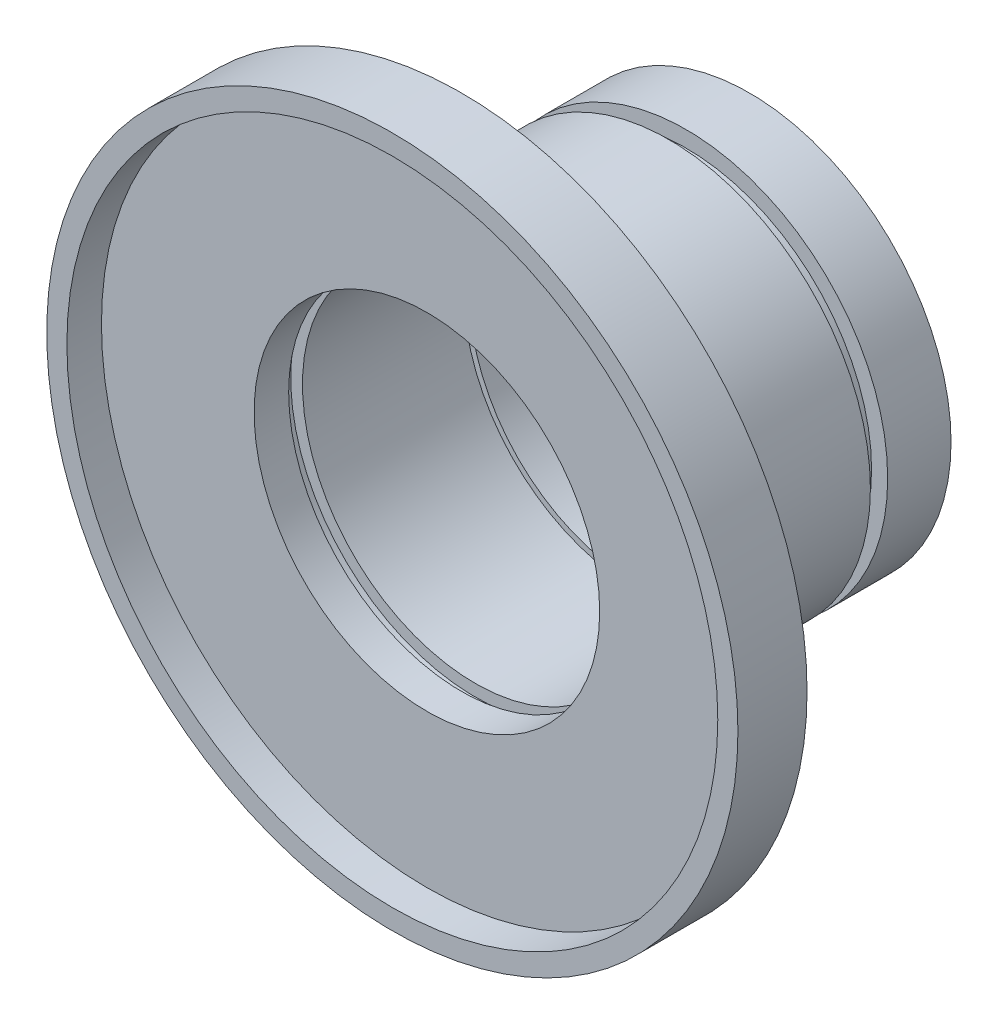
from build123d import *

# Parameters (mm, degrees)
SKETCH_1_R          = 30
SKETCH_1_R_2        = 28.251
EXTRUDE_1_DEPTH     = 3
SKETCH_2_R          = 30
SKETCH_2_R_2        = 15
EXTRUDE_2_DEPTH     = 3
SKETCH_4_R          = 17.5
SKETCH_4_R_2        = 15
EXTRUDE_3_DEPTH     = 20
SKETCH_5_R          = 17.5
SKETCH_5_R_2        = 14.5
EXTRUDE_4_DEPTH     = 0.5
SKETCH_6_W          = 1.5
SKETCH_6_H          = 1.4
SKETCH_7_W          = 1.2
SKETCH_7_H          = 1.05
SKETCH_8_R          = 15
SKETCH_8_R_2        = 14.5
EXTRUDE_5_DEPTH     = 4.8
SKETCH_9_R          = 17.5
SKETCH_9_R_2        = 11.5
EXTRUDE_6_DEPTH     = 4.5
CUT_EXTRUDE_1_DEPTH = 5


with BuildPart() as part:
    # 草图1 → 凸台-拉伸1 (new body)
    with BuildSketch(Plane.XY):
        Circle(SKETCH_1_R)
        Circle(SKETCH_1_R_2, mode=Mode.SUBTRACT)
    extrude(amount=EXTRUDE_1_DEPTH)

    # 草图2 → 凸台-拉伸2 (add)
    with BuildSketch(Plane.XY):
        Circle(SKETCH_2_R)
        Circle(SKETCH_2_R_2, mode=Mode.SUBTRACT)
    extrude(amount=-EXTRUDE_2_DEPTH)

    # 草图4 → 凸台-拉伸3 (add)
    with BuildSketch(Plane(origin=(0, 0, -3), x_dir=(-1, 0, 0), z_dir=(0, 0, -1))):
        Circle(SKETCH_4_R)
        Circle(SKETCH_4_R_2, mode=Mode.SUBTRACT)
    extrude(amount=EXTRUDE_3_DEPTH)

    # 草图5 → 凸台-拉伸4 (add)
    with BuildSketch(Plane(origin=(0, 0, -23), x_dir=(-1, 0, 0), z_dir=(0, 0, -1))):
        Circle(SKETCH_5_R)
        Circle(SKETCH_5_R_2, mode=Mode.SUBTRACT)
    extrude(amount=EXTRUDE_4_DEPTH)

    # 草图6 → 切除-旋转1 (revolve, cut)
    with BuildSketch(Plane(origin=(0, 0, 0), x_dir=(0, 0, -1), z_dir=(1, 0, 0))):
        with Locations((21.75, 16.8)):
            Rectangle(SKETCH_6_W, SKETCH_6_H)
    revolve(axis=Axis((0, 0, 3), (0, 0, -1)), mode=Mode.SUBTRACT)

    # 草图7 → 切除-旋转2 (revolve, cut)
    with BuildSketch(Plane(origin=(0, 0, 0), x_dir=(0, 0, -1), z_dir=(1, 0, 0))):
        with Locations((3.6, 15.498648932)):
            Rectangle(SKETCH_7_W, SKETCH_7_H)
    revolve(axis=Axis((0, 0, 3), (0, 0, -1)), mode=Mode.SUBTRACT)

    # 草图8 → 凸台-拉伸5 (add)
    with BuildSketch(Plane(origin=(0, 0, -23), x_dir=(-1, 0, 0), z_dir=(0, 0, -1))):
        Circle(SKETCH_8_R)
        Circle(SKETCH_8_R_2, mode=Mode.SUBTRACT)
    extrude(amount=-EXTRUDE_5_DEPTH)

    # 草图9 → 凸台-拉伸6 (add)
    with BuildSketch(Plane(origin=(0, 0, -23.5), x_dir=(-1, 0, 0), z_dir=(0, 0, -1))):
        Circle(SKETCH_9_R)
        Circle(SKETCH_9_R_2, mode=Mode.SUBTRACT)
    extrude(amount=EXTRUDE_6_DEPTH)

    # 草图10 → 切除-拉伸1 (cut)
    with BuildSketch(Plane(origin=(0, 0, -28), x_dir=(-1, 0, 0), z_dir=(0, 0, -1))):
        with BuildLine():
            ThreePointArc((-1.5, 11.401754251), (0, 11.5), (1.5, 11.401754251))
            Line((1.5, 11.401754251), (1.5, 13.5))
            Line((1.5, 13.5), (1.5, 15.427248621))
            ThreePointArc((1.5, 15.427248621), (0, 15.5), (-1.5, 15.427248621))
            Line((-1.5, 15.427248621), (-1.5, 13.5))
            Line((-1.5, 13.5), (-1.5, 11.401754251))
        make_face()
        with BuildLine():
            Line((6.414586205, 14.110389216), (5.450961894, 12.441342951))
            Line((5.450961894, 12.441342951), (4.40183902, 10.624208829))
            ThreePointArc((4.40183902, 10.624208829), (5.75, 9.959292144), (6.999915231, 9.124208829))
            Line((6.999915231, 9.124208829), (8.049038106, 10.941342951))
            Line((8.049038106, 10.941342951), (9.012662416, 12.610389216))
            ThreePointArc((9.012662416, 12.610389216), (7.75, 13.423393759), (6.414586205, 14.110389216))
        make_face()
        with BuildLine():
            Line((10.941342951, 8.049038106), (9.124208829, 6.999915231))
            ThreePointArc((9.124208829, 6.999915231), (9.959292144, 5.75), (10.624208829, 4.40183902))
            Line((10.624208829, 4.40183902), (12.441342951, 5.450961894))
            Line((12.441342951, 5.450961894), (14.110389216, 6.414586205))
            ThreePointArc((14.110389216, 6.414586205), (13.423393759, 7.75), (12.610389216, 9.012662416))
            Line((12.610389216, 9.012662416), (10.941342951, 8.049038106))
        make_face()
        with BuildLine():
            Line((13.5, 1.5), (11.401754251, 1.5))
            ThreePointArc((11.401754251, 1.5), (11.475412278, 0.751606983), (11.5, 0))
            ThreePointArc((11.5, 0), (11.475412278, -0.751606983), (11.401754251, -1.5))
            Line((11.401754251, -1.5), (13.5, -1.5))
            Line((13.5, -1.5), (15.427248621, -1.5))
            ThreePointArc((15.427248621, -1.5), (15.481801472, -0.750881609), (15.5, 0))
            ThreePointArc((15.5, 0), (15.481801472, 0.750881609), (15.427248621, 1.5))
            Line((15.427248621, 1.5), (13.5, 1.5))
        make_face()
        with BuildLine():
            Line((12.441342951, -5.450961894), (10.624208829, -4.40183902))
            ThreePointArc((10.624208829, -4.40183902), (9.959292144, -5.75), (9.124208829, -6.999915231))
            Line((9.124208829, -6.999915231), (10.941342951, -8.049038106))
            Line((10.941342951, -8.049038106), (12.610389216, -9.012662416))
            ThreePointArc((12.610389216, -9.012662416), (13.423393759, -7.75), (14.110389216, -6.414586205))
            Line((14.110389216, -6.414586205), (12.441342951, -5.450961894))
        make_face()
        with BuildLine():
            Line((8.049038106, -10.941342951), (6.999915231, -9.124208829))
            ThreePointArc((6.999915231, -9.124208829), (5.75, -9.959292144), (4.40183902, -10.624208829))
            Line((4.40183902, -10.624208829), (5.450961894, -12.441342951))
            Line((5.450961894, -12.441342951), (6.414586205, -14.110389216))
            ThreePointArc((6.414586205, -14.110389216), (7.75, -13.423393759), (9.012662416, -12.610389216))
            Line((9.012662416, -12.610389216), (8.049038106, -10.941342951))
        make_face()
        with BuildLine():
            Line((1.5, -13.5), (1.5, -11.401754251))
            ThreePointArc((1.5, -11.401754251), (0, -11.5), (-1.5, -11.401754251))
            Line((-1.5, -11.401754251), (-1.5, -13.5))
            Line((-1.5, -13.5), (-1.5, -15.427248621))
            ThreePointArc((-1.5, -15.427248621), (0, -15.5), (1.5, -15.427248621))
            Line((1.5, -15.427248621), (1.5, -13.5))
        make_face()
        with BuildLine():
            ThreePointArc((-4.40183902, -10.624208829), (-5.75, -9.959292144), (-6.999915231, -9.124208829))
            Line((-6.999915231, -9.124208829), (-8.049038106, -10.941342951))
            Line((-8.049038106, -10.941342951), (-9.012662416, -12.610389216))
            ThreePointArc((-9.012662416, -12.610389216), (-7.75, -13.423393759), (-6.414586205, -14.110389216))
            Line((-6.414586205, -14.110389216), (-5.450961894, -12.441342951))
            Line((-5.450961894, -12.441342951), (-4.40183902, -10.624208829))
        make_face()
        with BuildLine():
            ThreePointArc((-9.124208829, -6.999915231), (-9.959292144, -5.75), (-10.624208829, -4.40183902))
            Line((-10.624208829, -4.40183902), (-12.441342951, -5.450961894))
            Line((-12.441342951, -5.450961894), (-14.110389216, -6.414586205))
            ThreePointArc((-14.110389216, -6.414586205), (-13.423393759, -7.75), (-12.610389216, -9.012662416))
            Line((-12.610389216, -9.012662416), (-10.941342951, -8.049038106))
            Line((-10.941342951, -8.049038106), (-9.124208829, -6.999915231))
        make_face()
        with BuildLine():
            ThreePointArc((-11.401754251, -1.5), (-11.5, 0), (-11.401754251, 1.5))
            Line((-11.401754251, 1.5), (-13.5, 1.5))
            Line((-13.5, 1.5), (-15.427248621, 1.5))
            ThreePointArc((-15.427248621, 1.5), (-15.5, 0), (-15.427248621, -1.5))
            Line((-15.427248621, -1.5), (-13.5, -1.5))
            Line((-13.5, -1.5), (-11.401754251, -1.5))
        make_face()
        with BuildLine():
            ThreePointArc((-10.624208829, 4.40183902), (-9.959292144, 5.75), (-9.124208829, 6.999915231))
            Line((-9.124208829, 6.999915231), (-10.941342951, 8.049038106))
            Line((-10.941342951, 8.049038106), (-12.610389216, 9.012662416))
            ThreePointArc((-12.610389216, 9.012662416), (-13.423393759, 7.75), (-14.110389216, 6.414586205))
            Line((-14.110389216, 6.414586205), (-12.441342951, 5.450961894))
            Line((-12.441342951, 5.450961894), (-10.624208829, 4.40183902))
        make_face()
        with BuildLine():
            ThreePointArc((-6.999915231, 9.124208829), (-5.75, 9.959292144), (-4.40183902, 10.624208829))
            Line((-4.40183902, 10.624208829), (-5.450961894, 12.441342951))
            Line((-5.450961894, 12.441342951), (-6.414586205, 14.110389216))
            ThreePointArc((-6.414586205, 14.110389216), (-7.75, 13.423393759), (-9.012662416, 12.610389216))
            Line((-9.012662416, 12.610389216), (-8.049038106, 10.941342951))
            Line((-8.049038106, 10.941342951), (-6.999915231, 9.124208829))
        make_face()
    extrude(amount=-CUT_EXTRUDE_1_DEPTH, mode=Mode.SUBTRACT)


solid = part.part
